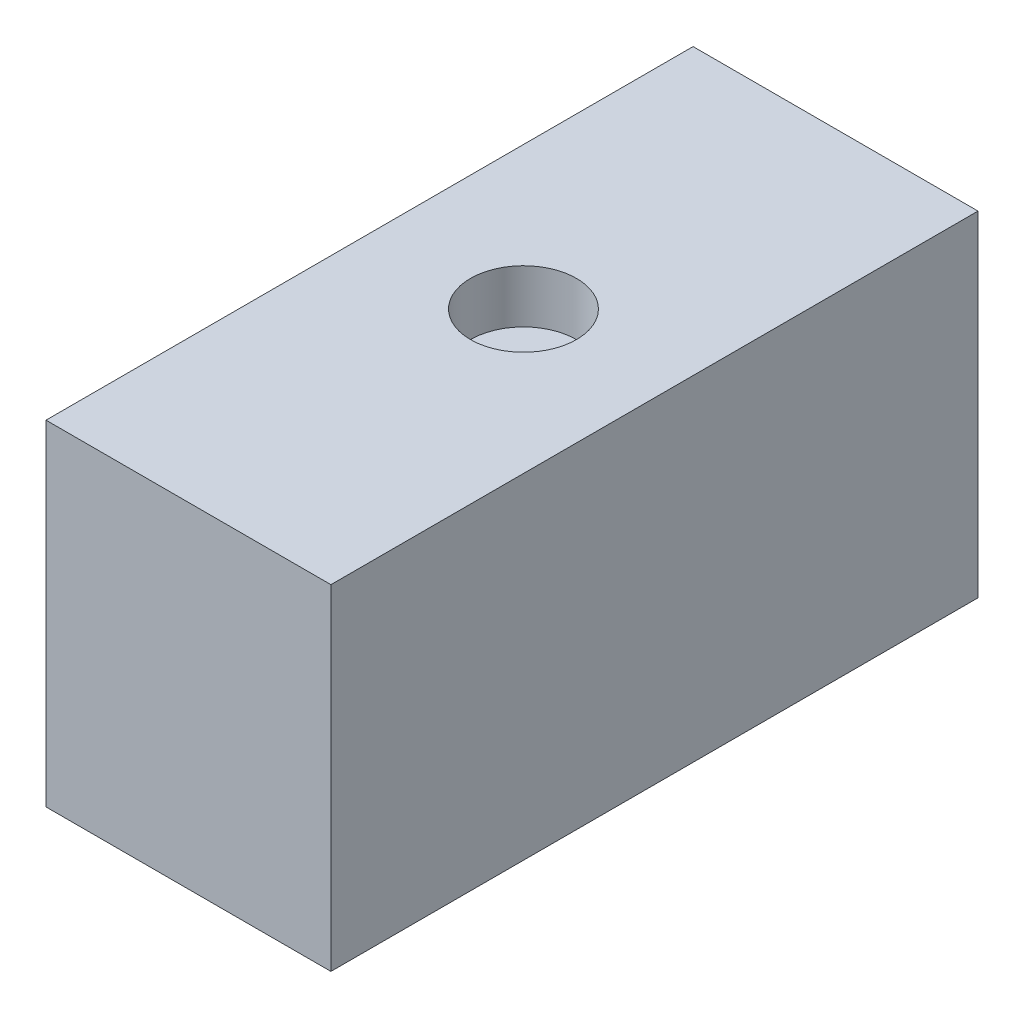
from build123d import *

# Parameters (mm, degrees)
SKETCH1_W           = 136.4996
SKETCH1_H           = 310.007
BOSS_EXTRUDE1_DEPTH = 160.4772
SKETCH4_R           = 25.4
CUT_EXTRUDE1_DEPTH  = 25.4


with BuildPart() as part:
    # Sketch1 → Boss-Extrude1 (new body)
    with BuildSketch(Plane(origin=(0, 0, 0), x_dir=(1, 0, 0), z_dir=(0, 1, 0))):
        with Locations((68.2498, 155.0035)):
            Rectangle(SKETCH1_W, SKETCH1_H)
    extrude(amount=BOSS_EXTRUDE1_DEPTH)

    # Sketch4 → Cut-Extrude1 (cut)
    with BuildSketch(Plane(origin=(0, 160.4772, 0), x_dir=(1, 0, 0), z_dir=(0, 1, 0))):
        with Locations((68.2498, 160.5026)):
            Circle(SKETCH4_R)
    extrude(amount=-CUT_EXTRUDE1_DEPTH, mode=Mode.SUBTRACT)


solid = part.part
